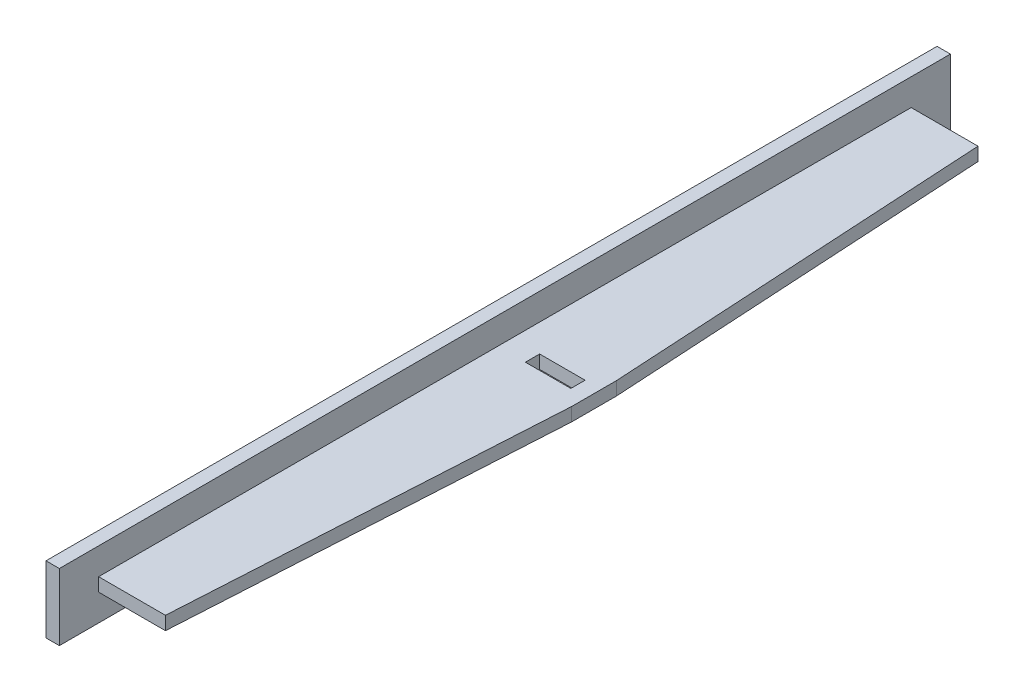
from build123d import *

# Parameters (mm, degrees)
SKETCH_1_W          = 3
SKETCH_1_H          = 15
EXTRUDE_1_DEPTH     = 200
EXTRUDE_7_DEPTH     = 3
SKETCH_13_W         = 10.2
SKETCH_13_H         = 3.2
CUT_EXTRUDE_2_DEPTH = 23


with BuildPart() as part:
    # 草图1 → 凸台-拉伸1 (new body)
    with BuildSketch(Plane.XY):
        with Locations((1.5, 7.5)):
            Rectangle(SKETCH_1_W, SKETCH_1_H)
    extrude(amount=EXTRUDE_1_DEPTH)

    # 草图12 → 凸台-拉伸7 (add)
    with BuildSketch(Plane(origin=(0, 9, 0), x_dir=(1, 0, 0), z_dir=(0, 1, 0))):
        Polygon((18, -191.190016229), (23, -105), (23, -95), (18, -8.809983771), (3, -8.809983771), (3, -191.190016229), align=None)
    extrude(amount=-EXTRUDE_7_DEPTH)

    # 草图13 → 切除-拉伸2 (cut)
    with BuildSketch(Plane.XZ.offset(-6)):
        with Locations((14.3, 100)):
            Rectangle(SKETCH_13_W, SKETCH_13_H)
    extrude(amount=-CUT_EXTRUDE_2_DEPTH, mode=Mode.SUBTRACT)


solid = part.part
